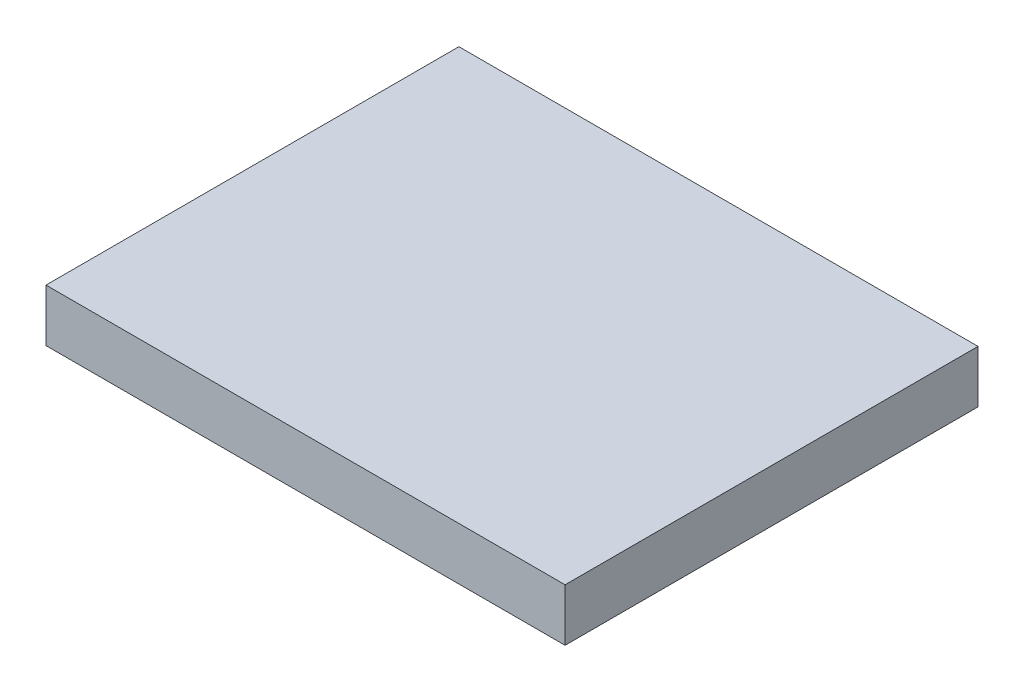
from build123d import *

# Parameters (mm, degrees)
SKETCH1_W           = 440
SKETCH1_H           = 350
BOSS_EXTRUDE1_DEPTH = 44.45


with BuildPart() as part:
    # Sketch1 → Boss-Extrude1 (new body)
    with BuildSketch(Plane(origin=(0, 0, 0), x_dir=(1, 0, 0), z_dir=(0, 1, 0))):
        Rectangle(SKETCH1_W, SKETCH1_H)
    extrude(amount=BOSS_EXTRUDE1_DEPTH)


solid = part.part
